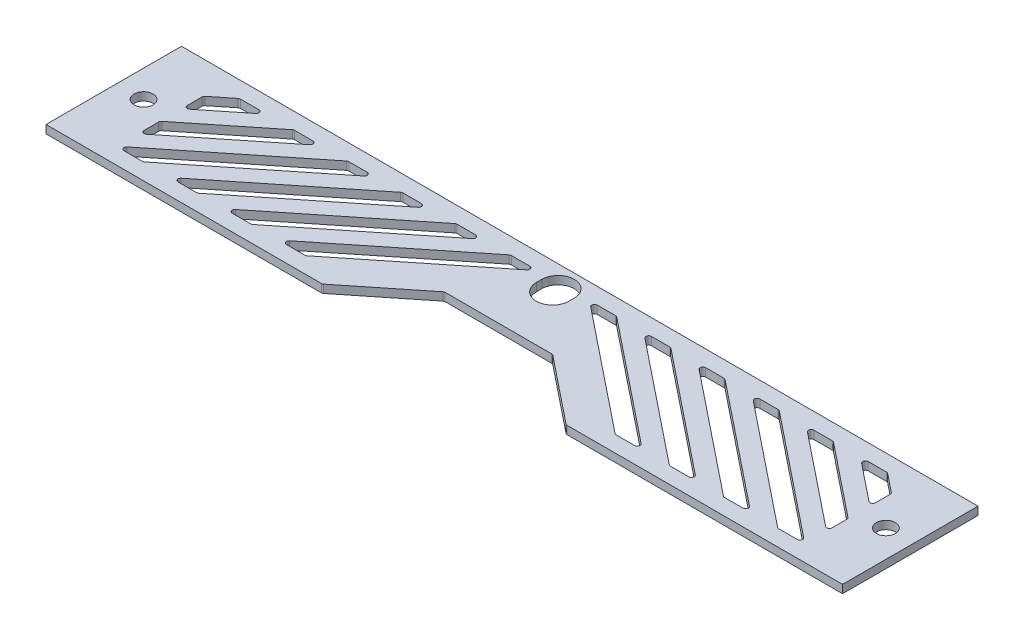
from build123d import *

# Parameters (mm, degrees)
SKETCH_1_W          = 147
SKETCH_1_H          = 25
EXTRUDE_1_DEPTH     = 1.5
CUT_EXTRUDE_1_DEPTH = 2.5
CUT_EXTRUDE_2_DEPTH = 10
FILLET_2_R          = 0.5
SKETCH_4_W          = 10
SKETCH_4_H          = 25
EXTRUDE_2_DEPTH     = 1.5
FILLET_3_R          = 0.5
SKETCH_5_R          = 1.75
CUT_EXTRUDE_3_DEPTH = 2.5
CUT_EXTRUDE_4_DEPTH = 2.5


with BuildPart() as part:
    # 草图1 → 凸台-拉伸1 (new body)
    with BuildSketch(Plane(origin=(0, 0, 0), x_dir=(1, 0, 0), z_dir=(0, 1, 0))):
        Rectangle(SKETCH_1_W, SKETCH_1_H)
    extrude(amount=EXTRUDE_1_DEPTH)

    # 草图2 → 切除-拉伸1 (cut, through all)
    with BuildSketch(Plane.XZ):
        Polygon((10, 2.5), (-10, 2.5), (-22.5, 12.5), (22.5, 12.5), align=None)
    extrude(amount=-CUT_EXTRUDE_1_DEPTH, mode=Mode.SUBTRACT)

    # 草图3 → 切除-拉伸2 (cut)
    with BuildSketch(Plane.XZ):
        Polygon((-4.802343178, -9.5), (-16.052343178, -0.5), (-28.552343178, 9.5), (-33.552343178, 9.5), (-21.052343178, -0.5), (-9.802343178, -9.5), align=None)
        Polygon((-26.052343178, -0.5), (-38.552343178, 9.5), (-43.552343178, 9.5), (-31.052343178, -0.5), (-19.802343178, -9.5), (-14.802343178, -9.5), align=None)
        Polygon((-36.052343178, -0.5), (-48.552343178, 9.5), (-53.552343178, 9.5), (-41.052343178, -0.5), (-29.802343178, -9.5), (-24.802343178, -9.5), align=None)
        Polygon((-46.052343178, -0.5), (-58.552343178, 9.5), (-63.552343178, 9.5), (-51.052343178, -0.5), (-39.802343178, -9.5), (-34.802343178, -9.5), align=None)
        Polygon((-56.052343178, -0.5), (-68.552343178, 9.5), (-70.5, 9.5), (-70.5, 7.058125458), (-61.052343178, -0.5), (-49.802343178, -9.5), (-44.802343178, -9.5), align=None)
        Polygon((-59.802343178, -9.5), (-54.802343178, -9.5), (-66.052343178, -0.5), (-70.5, 3.058125458), (-70.5, -0.941874542), align=None)
        Polygon((-70.5, -9.5), (-64.802343178, -9.5), (-70.5, -4.941874542), align=None)
    cut_extrude_2 = extrude(amount=-CUT_EXTRUDE_2_DEPTH, mode=Mode.SUBTRACT)

    # 镜向3: 切除-拉伸2 across plane
    add(cut_extrude_2.mirror(Plane(origin=(0, 0, 0), x_dir=(0, 0, 1), z_dir=(1, 0, 0))), mode=Mode.SUBTRACT)

    # 圆角2
    fillet_2_edges = [part.edges().sort_by_distance(p)[0] for p in [
        (-70.5, 0.75, -0.941874542),
        (-70.5, 0.75, 3.058125458),
        (-54.802343178, 0.75, -9.5),
        (-59.802343178, 0.75, -9.5),
        (-9.802343178, 0.75, -9.5),
        (-33.552343178, 0.75, 9.5),
        (-28.552343178, 0.75, 9.5),
        (-4.802343178, 0.75, -9.5),
        (22.5, 0.75, 12.5),
        (10, 0.75, 2.5),
        (-10, 0.75, 2.5),
        (-22.5, 0.75, 12.5),
        (63.552343178, 0.75, 9.5),
        (39.802343178, 0.75, -9.5),
        (34.802343178, 0.75, -9.5),
        (58.552343178, 0.75, 9.5),
        (70.5, 0.75, 7.058125458),
        (49.802343178, 0.75, -9.5),
        (44.802343178, 0.75, -9.5),
        (68.552343178, 0.75, 9.5),
        (70.5, 0.75, 9.5),
        (43.552343178, 0.75, 9.5),
        (19.802343178, 0.75, -9.5),
        (14.802343178, 0.75, -9.5),
        (38.552343178, 0.75, 9.5),
        (53.552343178, 0.75, 9.5),
        (29.802343178, 0.75, -9.5),
        (24.802343178, 0.75, -9.5),
        (48.552343178, 0.75, 9.5),
        (64.802343178, 0.75, -9.5),
        (70.5, 0.75, -4.941874542),
        (70.5, 0.75, -9.5),
        (70.5, 0.75, 3.058125458),
        (70.5, 0.75, -0.941874542),
        (59.802343178, 0.75, -9.5),
        (54.802343178, 0.75, -9.5),
        (33.552343178, 0.75, 9.5),
        (9.802343178, 0.75, -9.5),
        (4.802343178, 0.75, -9.5),
        (28.552343178, 0.75, 9.5),
        (-39.802343178, 0.75, -9.5),
        (-63.552343178, 0.75, 9.5),
        (-58.552343178, 0.75, 9.5),
        (-34.802343178, 0.75, -9.5),
        (-49.802343178, 0.75, -9.5),
        (-70.5, 0.75, 7.058125458),
        (-70.5, 0.75, 9.5),
        (-68.552343178, 0.75, 9.5),
        (-44.802343178, 0.75, -9.5),
        (73.5, 0.75, 12.5),
        (-19.802343178, 0.75, -9.5),
        (-73.5, 0.75, 12.5),
        (-43.552343178, 0.75, 9.5),
        (-38.552343178, 0.75, 9.5),
        (-14.802343178, 0.75, -9.5),
        (-73.5, 0.75, -12.5),
        (73.5, 0.75, -12.5),
        (-29.802343178, 0.75, -9.5),
        (-53.552343178, 0.75, 9.5),
        (-48.552343178, 0.75, 9.5),
        (-24.802343178, 0.75, -9.5),
        (-70.5, 0.75, -4.941874542),
        (-64.802343178, 0.75, -9.5),
        (-70.5, 0.75, -9.5),
    ]]
    fillet(fillet_2_edges, radius=FILLET_2_R)

    # 草图4 → 凸台-拉伸2 (add)
    with BuildSketch(Plane(origin=(0, 1.5, 0), x_dir=(1, 0, 0), z_dir=(0, 1, 0))):
        with Locations((68.5, 0)):
            Rectangle(SKETCH_4_W, SKETCH_4_H)
    extrude_2 = extrude(amount=-EXTRUDE_2_DEPTH)

    # 镜向4: 凸台-拉伸2 across plane
    add(extrude_2.mirror(Plane(origin=(0, 0, 0), x_dir=(0, 0, 1), z_dir=(1, 0, 0))))

    # 圆角3
    fillet_3_edges = [part.edges().sort_by_distance(p)[0] for p in [
        (63.5, 0.75, 5.458125458),
        (63.5, 0.75, -6.541874542),
        (63.5, 0.75, -2.541874542),
        (63.5, 0.75, 1.458125458),
        (-63.5, 0.75, 5.458125458),
        (-63.5, 0.75, -2.541874542),
        (-63.5, 0.75, 1.458125458),
        (-63.5, 0.75, -6.541874542),
    ]]
    fillet(fillet_3_edges, radius=FILLET_3_R)

    # 草图5 → 切除-拉伸3 (cut, through all)
    with BuildSketch(Plane.XZ):
        with Locations((-68.5, -0.5)):
            Circle(SKETCH_5_R)
        with Locations((68.5, -0.5)):
            Circle(SKETCH_5_R)
    extrude(amount=-CUT_EXTRUDE_3_DEPTH, mode=Mode.SUBTRACT)

    # 草图6 → 切除-拉伸4 (cut, through all)
    with BuildSketch(Plane(origin=(0, 1.5, 0), x_dir=(1, 0, 0), z_dir=(0, 1, 0))):
        with BuildLine():
            Line((3, 8.5), (3, 7.5))
            ThreePointArc((3, 7.5), (0, 4.5), (-3, 7.5))
            Line((-3, 7.5), (-3, 8.5))
            ThreePointArc((-3, 8.5), (0, 11.5), (3, 8.5))
        make_face()
    extrude(amount=-CUT_EXTRUDE_4_DEPTH, mode=Mode.SUBTRACT)


solid = part.part
